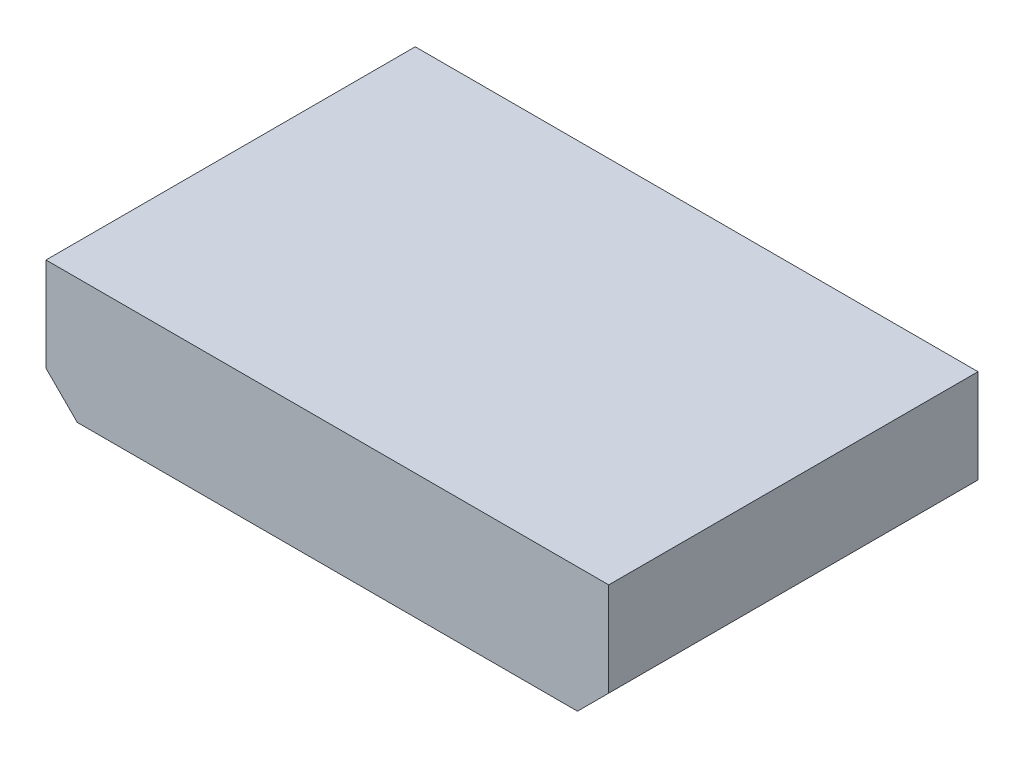
from build123d import *

# Parameters (mm, degrees)
COMPONENT_OUTLINE_DEPTH = 15
SKETCH2_R               = 0.25
EXTRUDE_1_DEPTH         = 2
SKETCH3_R               = 0.25
EXTRUDE_2_DEPTH         = 2
SKETCH4_R               = 0.25
EXTRUDE_3_DEPTH         = 2
SKETCH5_R               = 0.25
EXTRUDE_4_DEPTH         = 2
SKETCH6_R               = 0.25
EXTRUDE_5_DEPTH         = 2
SKETCH7_R               = 0.25
EXTRUDE_6_DEPTH         = 2


with BuildPart() as part:
    # Sketch1 → Component_Outline (new body)
    with BuildSketch(Plane.XY):
        Polygon((-5.08, 2.54), (-5.08, -1.27), (-3.81, -2.54), (16.51, -2.54), (17.78, -1.27), (17.78, 2.54), align=None)
    extrude(amount=COMPONENT_OUTLINE_DEPTH)


with BuildPart() as body_2:
    # Sketch2 → Extrude 1 (new body)
    with BuildSketch(Plane.XY):
        Circle(SKETCH2_R)
    extrude(amount=-EXTRUDE_1_DEPTH)


with BuildPart() as body_3:
    # Sketch3 → Extrude 2 (new body)
    with BuildSketch(Plane.XY):
        with Locations((2.54, 0)):
            Circle(SKETCH3_R)
    extrude(amount=-EXTRUDE_2_DEPTH)


with BuildPart() as body_4:
    # Sketch4 → Extrude 3 (new body)
    with BuildSketch(Plane.XY):
        with Locations((5.08, 0)):
            Circle(SKETCH4_R)
    extrude(amount=-EXTRUDE_3_DEPTH)


with BuildPart() as body_5:
    # Sketch5 → Extrude 4 (new body)
    with BuildSketch(Plane.XY):
        with Locations((7.62, 0)):
            Circle(SKETCH5_R)
    extrude(amount=-EXTRUDE_4_DEPTH)


with BuildPart() as body_6:
    # Sketch6 → Extrude 5 (new body)
    with BuildSketch(Plane.XY):
        with Locations((10.16, 0)):
            Circle(SKETCH6_R)
    extrude(amount=-EXTRUDE_5_DEPTH)


with BuildPart() as body_7:
    # Sketch7 → Extrude 6 (new body)
    with BuildSketch(Plane.XY):
        with Locations((12.7, 0)):
            Circle(SKETCH7_R)
    extrude(amount=-EXTRUDE_6_DEPTH)


solid = Compound([part.part, body_2.part, body_3.part, body_4.part, body_5.part, body_6.part, body_7.part])
